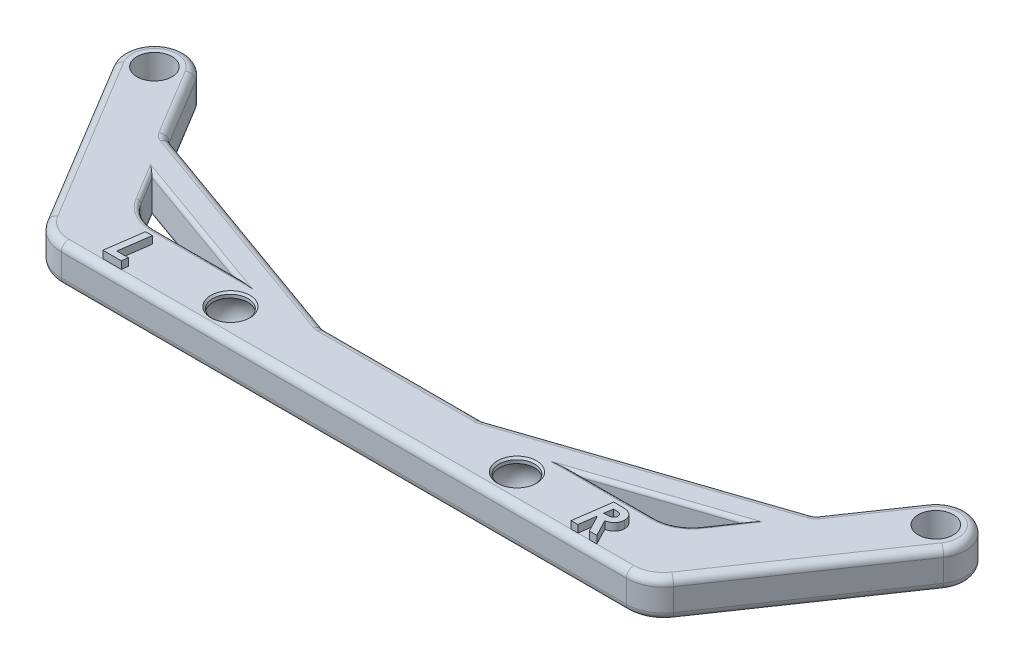
from build123d import *

# Parameters (mm, degrees)
SKETCH1_R           = 2.35
BOSS_EXTRUDE1_DEPTH = 5
FILLET2_R           = 0.5
FILLET3_R           = 1
CHAMFER1_SIZE       = 0.25
BOSS_EXTRUDE2_DEPTH = 1


with BuildPart() as part:
    # Sketch1 → Boss-Extrude1 (new body)
    with BuildSketch(Plane(origin=(0, 0, 0), x_dir=(1, 0, 0), z_dir=(0, 1, 0))):
        with BuildLine():
            Line((50.042101864, 24.174387827), (43.893327684, 15.17666591))
            Line((43.893327684, 15.17666591), (10.68341508, 4))
            Line((10.68341508, 4), (-10.68341508, 4))
            Line((-10.68341508, 4), (-43.112975931, 15.605727248))
            Line((-43.112975931, 15.605727248), (-48.658723515, 24.7949577))
            ThreePointArc((-48.658723515, 24.7949577), (-54.150190612, 26.152819669), (-55.50805258, 20.661352572))
            Line((-55.50805258, 20.661352572), (-42.083168328, -1.583503205))
            ThreePointArc((-42.083168328, -1.583503205), (-40.260231474, -3.354165593), (-37.802337662, -4))
            Line((-37.802337662, -4), (37.839004699, -4))
            ThreePointArc((37.839004699, -4), (40.172962707, -3.421836724), (41.967157192, -1.821056007))
            Line((41.967157192, -1.821056007), (56.647145853, 19.660698216))
            ThreePointArc((56.647145853, 19.660698216), (55.601468664, 25.220065016), (50.042101864, 24.174387827))
        make_face()
        with BuildLine():
            Line((-22.55469609, 4), (-33.28639768, 4))
            ThreePointArc((-33.28639768, 4), (-35.744291491, 4.645834407), (-37.567228346, 6.416496795))
            Line((-37.567228346, 6.416496795), (-39.842715522, 10.186948972))
            Line((-39.842715522, 10.186948972), (-22.55469609, 4))
        make_face(mode=Mode.SUBTRACT)
        with BuildLine():
            ThreePointArc((-21.18341508, 0), (-19.18341508, 2), (-17.18341508, 0))
            ThreePointArc((-17.18341508, 0), (-19.18341508, -2), (-21.18341508, 0))
        make_face(mode=Mode.SUBTRACT)
        with BuildLine():
            ThreePointArc((21.18341508, 0), (19.18341508, -2), (17.18341508, 0))
            ThreePointArc((17.18341508, 0), (19.18341508, 2), (21.18341508, 0))
        make_face(mode=Mode.SUBTRACT)
        with BuildLine():
            Line((40.147774043, 9.695662853), (37.744553503, 6.178943993))
            ThreePointArc((37.744553503, 6.178943993), (35.950359018, 4.578163276), (33.61640101, 4))
            Line((33.61640101, 4), (23.223901836, 4))
            Line((23.223901836, 4), (40.147774043, 9.695662853))
        make_face(mode=Mode.SUBTRACT)
        with Locations(Location((-52.083388048, 22.728155136, 0), (0, 0, 270))):
            Circle(SKETCH1_R, mode=Mode.SUBTRACT)
        with Locations(Location((53.344623859, 21.917543022, 0), (0, 0, 270))):
            Circle(SKETCH1_R, mode=Mode.SUBTRACT)
    extrude(amount=BOSS_EXTRUDE1_DEPTH)

    # Fillet2
    fillet2_edges = [part.edges().sort_by_distance(p)[0] for p in [
        (-31.198705806, 5, -7.093474486),
        (-27.920546885, 5, -4),
        (-35.744291491, 5, -4.645834407),
        (-38.704971934, 5, -8.301722884),
        (-38.704971934, 0, -8.301722884),
        (-35.744291491, 0, -4.645834407),
        (-27.920546885, 0, -4),
        (-31.198705806, 0, -7.093474486),
        (28.420151423, 0, -4),
        (35.950359018, 0, -4.578163276),
        (38.946163773, 0, -7.937303423),
        (31.68583794, 0, -6.847831427),
        (31.68583794, 5, -6.847831427),
        (38.946163773, 5, -7.937303423),
        (35.950359018, 5, -4.578163276),
        (28.420151423, 5, -4),
    ]]
    fillet(fillet2_edges, radius=FILLET2_R)

    # Fillet3
    fillet3_edges = [part.edges().sort_by_distance(p)[0] for p in [
        (46.967714774, 5, -19.675526869),
        (27.288371382, 5, -9.588332955),
        (0, 5, -4),
        (-26.898195505, 5, -9.802863624),
        (-45.885849723, 5, -20.200342474),
        (55.601468664, 0, -25.220065016),
        (49.307151523, 0, -8.919821105),
        (40.172962707, 0, 3.421836724),
        (0.018333518, 0, 4),
        (-40.260231474, 0, 3.354165593),
        (-48.795610454, 0, -9.538924684),
        (-54.150190612, 0, -26.152819669),
        (-54.150190612, 5, -26.152819669),
        (-45.885849723, 0, -20.200342474),
        (-26.898195505, 0, -9.802863624),
        (0, 0, -4),
        (27.288371382, 0, -9.588332955),
        (46.967714774, 0, -19.675526869),
        (-48.795610454, 5, -9.538924684),
        (-40.260231474, 5, 3.354165593),
        (-43.112975931, 2.5, -15.605727248),
        (-10.68341508, 2.5, -4),
        (10.68341508, 2.5, -4),
        (43.893327684, 2.5, -15.17666591),
        (0.018333518, 5, 4),
        (40.172962707, 5, 3.421836724),
        (49.307151523, 5, -8.919821105),
        (55.601468664, 5, -25.220065016),
    ]]
    fillet(fillet3_edges, radius=FILLET3_R)

    # Sketch2 → Cut-Revolve3 (revolve, cut)
    with BuildSketch(Plane.XY, mode=Mode.PRIVATE) as cut_revolve3_sk:
        with BuildLine():
            Line((-21.546060422, 5), (-21.546060422, 4.30790818))
            ThreePointArc((-21.546060422, 4.30790818), (-22.15841508, 2.5), (-21.546060422, 0.69209182))
            Line((-21.546060422, 0.69209182), (-21.546060422, 0))
            Line((-21.546060422, 0), (-19.18341508, 0))
            Line((-19.18341508, 0), (-19.18341508, 5))
            Line((-19.18341508, 5), (-21.546060422, 5))
        make_face()
    cut_revolve3 = revolve(cut_revolve3_sk.sketch.rotate(Axis((-19.18341508, 7.523248273, 0), (0, -1, 0)), 270), axis=Axis((-19.18341508, 7.523248273, 0), (0, -1, 0)), mode=Mode.SUBTRACT)

    # Mirror1: Cut-Revolve3 across plane
    add(cut_revolve3.mirror(Plane(origin=(0, 0, 0), x_dir=(0, 0, 1), z_dir=(1, 0, 0))), mode=Mode.SUBTRACT)

    # Chamfer1
    chamfer1_edges = [part.edges().sort_by_distance(p)[0] for p in [
        (-19.18341508, 0, -2.362645342),
        (-19.18341508, 5, -2.362645342),
        (19.18341508, 5, -2.362645342),
        (19.18341508, 0, -2.362645342),
    ]]
    chamfer(chamfer1_edges, length=CHAMFER1_SIZE)

    # Sketch3 → Boss-Extrude2 (add)
    with BuildSketch(Plane(origin=(0, 5, 0), x_dir=(1, 0, 0), z_dir=(0, 1, 0))):
        Polygon((-32.549775456, 2), (-31.642323533, 2), (-32.22725943, -2.166666667), (-30.686794687, -2.166666667), (-30.794967764, -3), (-33.250897251, -3), align=None)
        with BuildLine():
            Line((30.142532236, 2), (31.010921659, 2))
            add(Edge.make_bspline(
                [(31.010921659, 2), (31.075365543, 1.999736646), (31.199621096, 1.999228867), (31.378304625, 1.992008258), (31.542305706, 1.981114583), (31.691429334, 1.966738221), (31.825800014, 1.946791824), (31.945138312, 1.922842178), (32.05020647, 1.89617091), (32.113215473, 1.871386228), (32.142732557, 1.859775641)],
                knots=[0, 0, 0, 0, 1.348808202, 2.600664361, 3.742342956, 4.788858012, 5.735658768, 6.584006912, 7.336666444, 8, 8, 8, 8], degree=3))
            add(Edge.make_bspline(
                [(32.142732557, 1.859775641), (32.175964997, 1.844789398), (32.240929159, 1.815493664), (32.334019016, 1.765835598), (32.421190421, 1.712340384), (32.500998665, 1.652991077), (32.575127949, 1.590286684), (32.643118605, 1.523630806), (32.704423164, 1.452000479), (32.759685007, 1.376680489), (32.808823598, 1.297768252), (32.851004016, 1.214874628), (32.887476693, 1.128701418), (32.91595883, 1.038310906), (32.93963091, 0.944788129), (32.954941153, 0.847543021), (32.965715779, 0.746903607), (32.966601124, 0.678582599), (32.967051467, 0.643830128)],
                knots=[0, 0, 0, 0, 1.116361014, 2.182309107, 3.229450697, 4.24598407, 5.225421932, 6.201651319, 7.158895679, 8.110002388, 9.060669178, 10.002827475, 10.956240434, 11.923213192, 12.902917952, 13.908279153, 14.936015885, 16, 16, 16, 16], degree=3))
            add(Edge.make_bspline(
                [(32.967051467, 0.643830128), (32.965992373, 0.601064821), (32.96390155, 0.516639182), (32.95023967, 0.39214222), (32.924758569, 0.272674459), (32.890443209, 0.157859567), (32.847929234, 0.046954128), (32.793101901, -0.058112019), (32.729728322, -0.159169523), (32.656538306, -0.254893456), (32.574730841, -0.346161929), (32.480271881, -0.42760369), (32.378387029, -0.504695928), (32.264890712, -0.57226995), (32.142904359, -0.635040198), (32.009645634, -0.688222967), (31.867615595, -0.737302454), (31.768026721, -0.761866054), (31.717051467, -0.774439103)],
                knots=[0, 0, 0, 0, 0.995453645, 1.965186658, 2.910129054, 3.83459069, 4.752398018, 5.669942118, 6.588407184, 7.525617038, 8.471772905, 9.435289717, 10.423772802, 11.441988612, 12.505459691, 13.613754905, 14.778583949, 16, 16, 16, 16], degree=3))
            Line((31.717051467, -0.774439103), (32.870897621, -3))
            Line((32.870897621, -3), (31.868293454, -3))
            Line((31.868293454, -3), (30.738485762, -0.820512821))
            Line((30.738485762, -0.820512821), (30.654351147, -0.820512821))
            Line((30.654351147, -0.820512821), (30.346859159, -3))
            Line((30.346859159, -3), (29.441410441, -3))
            Line((29.441410441, -3), (30.142532236, 2))
        make_face()
        with BuildLine():
            add(Edge.make_bspline(
                [(30.771538647, 0.012820513), (30.835984696, 0.013417113), (30.959253776, 0.01455826), (31.135302787, 0.022543386), (31.293740499, 0.035017412), (31.434390485, 0.053166089), (31.557695525, 0.074321608), (31.663414571, 0.100866518), (31.75171383, 0.132414721), (31.823984238, 0.169830537), (31.882528302, 0.21375976), (31.933200691, 0.260639252), (31.975394575, 0.313115621), (32.010208309, 0.370307936), (32.037058996, 0.432334729), (32.056422492, 0.499616227), (32.067128723, 0.571703821), (32.068774577, 0.621427363), (32.06961557, 0.646834936)],
                knots=[0, 0, 0, 0, 1.89335902, 3.621519463, 5.176573087, 6.561132097, 7.786781855, 8.850229336, 9.759505088, 10.53614971, 11.230649399, 11.903761734, 12.55942339, 13.202041648, 13.865362736, 14.539046595, 15.253486819, 16, 16, 16, 16], degree=3))
            add(Edge.make_bspline(
                [(32.06961557, 0.646834936), (32.068526937, 0.675643454), (32.066415139, 0.73152803), (32.048148949, 0.812017946), (32.016914386, 0.88503319), (31.973018491, 0.949875902), (31.91823868, 1.007050421), (31.851410673, 1.054142457), (31.773296362, 1.091204052), (31.700126841, 1.115720613), (31.631178242, 1.12977549), (31.56665604, 1.139607628), (31.490171815, 1.148512428), (31.40163361, 1.155401007), (31.301412432, 1.159939655), (31.189240515, 1.164279751), (31.065011814, 1.165839826), (30.978202419, 1.16638271), (30.932796659, 1.166666667)],
                knots=[0, 0, 0, 0, 0.975025327, 1.891415476, 2.778007847, 3.650053007, 4.529910843, 5.446300992, 6.402314795, 7.450247022, 8.051382379, 8.78400578, 9.660805258, 10.659230114, 11.791644133, 13.059173022, 14.461796856, 16, 16, 16, 16], degree=3))
            Line((30.932796659, 1.166666667), (30.771538647, 0.012820513))
        make_face(mode=Mode.SUBTRACT)
    extrude(amount=BOSS_EXTRUDE2_DEPTH)


solid = part.part
